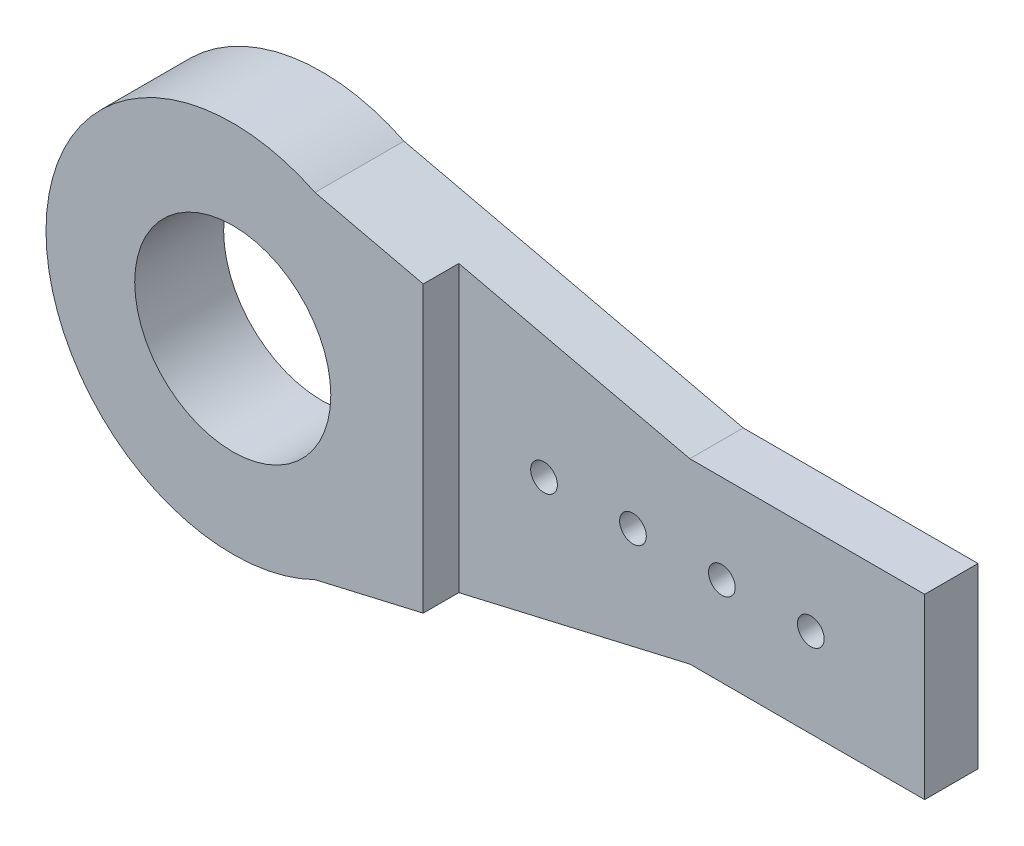
from build123d import *

# Parameters (mm, degrees)
IZIM1_R                     = 7.5
IZIM1_R_2                   = 1.5
Y_KSEKLIK_EKSTR_ZYON1_DEPTH = 10
KES_EKSTR_ZYON1_DEPTH       = 4
IZIM3_R                     = 11.025
KES_EKSTR_ZYON2_DEPTH       = 69


with BuildPart() as part:
    # Çizim1 → Yükseklik-Ekstrüzyon1 (new body)
    with BuildSketch(Plane.XY):
        with BuildLine():
            Line((-38.151258574, 18.853667601), (0, 10))
            Line((0, 10), (26.4, 10))
            Line((26.4, 10), (26.4, -10))
            Line((26.4, -10), (0, -10))
            Line((0, -10), (-38.151258574, -18.853667601))
            ThreePointArc((-38.151258574, -18.853667601), (-68.4, 0), (-38.151258574, 18.853667601))
        make_face()
        with Locations((-47.4, 0)):
            Circle(IZIM1_R, mode=Mode.SUBTRACT)
        with Locations((-16.4, 0)):
            Circle(IZIM1_R_2, mode=Mode.SUBTRACT)
        with Locations((-6.4, 0)):
            Circle(IZIM1_R_2, mode=Mode.SUBTRACT)
        with Locations((3.6, 0)):
            Circle(IZIM1_R_2, mode=Mode.SUBTRACT)
        with Locations((13.6, 0)):
            Circle(IZIM1_R_2, mode=Mode.SUBTRACT)
    extrude(amount=Y_KSEKLIK_EKSTR_ZYON1_DEPTH)

    # Çizim2 → Kes-Ekstrüzyon1 (cut)
    with BuildSketch(Plane.XY.offset(10)):
        Polygon((-25.98, -16.029113924), (0, -10), (26.4, -10), (26.4, 10), (0, 10), (-25.98, 16.029113924), align=None)
    extrude(amount=-KES_EKSTR_ZYON1_DEPTH, mode=Mode.SUBTRACT)

    # Çizim3 → Kes-Ekstrüzyon2 (cut)
    with BuildSketch(Plane.XY.offset(10)):
        with Locations((-47.4, 0)):
            Circle(IZIM3_R)
    extrude(amount=-KES_EKSTR_ZYON2_DEPTH, mode=Mode.SUBTRACT)


solid = part.part
